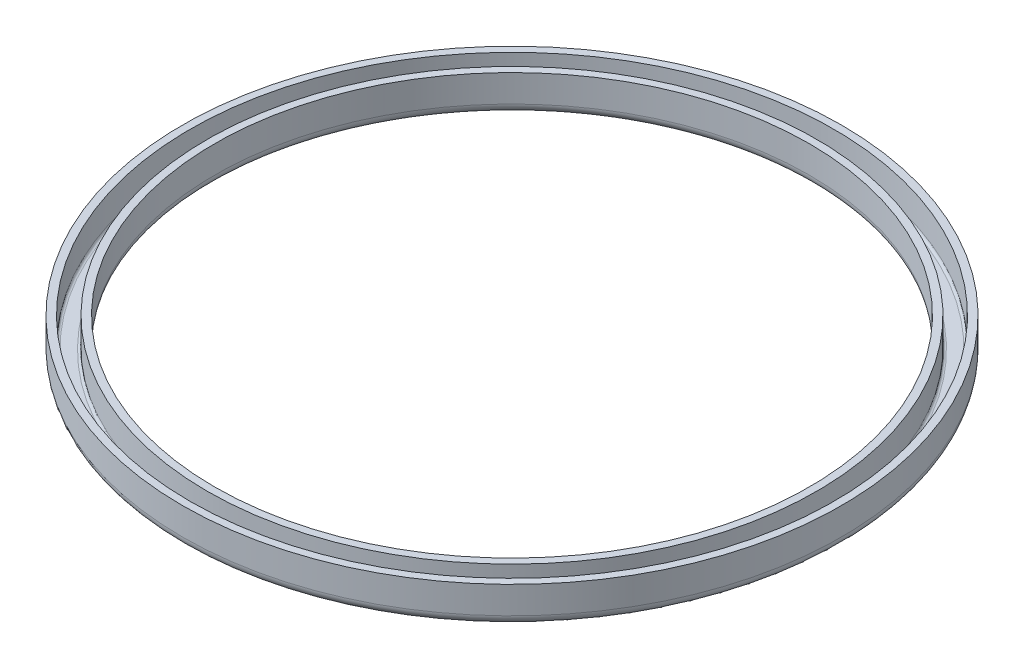
from build123d import *


with BuildPart() as part:
    # Sketch1 → Revolve-Thin1 (revolve)
    with BuildSketch(Plane.XY):
        with BuildLine():
            Line((-6.65, 0.75), (-6.65, 0.2))
            ThreePointArc((-6.65, 0.2), (-6.591421356, 0.058578644), (-6.45, 0))
            Line((-6.45, 0), (-6.2, 0))
            ThreePointArc((-6.2, 0), (-6.058578644, 0.058578644), (-6, 0.2))
            Line((-6, 0.2), (-6, 0.75))
            Line((-6, 0.75), (-6.15, 0.75))
            Line((-6.15, 0.75), (-6.15, 0.2))
            ThreePointArc((-6.15, 0.2), (-6.164644661, 0.164644661), (-6.2, 0.15))
            Line((-6.2, 0.15), (-6.45, 0.15))
            ThreePointArc((-6.45, 0.15), (-6.485355339, 0.164644661), (-6.5, 0.2))
            Line((-6.5, 0.2), (-6.5, 0.75))
            Line((-6.5, 0.75), (-6.65, 0.75))
        make_face()
    revolve(axis=Axis((0, 25.194951605, 0), (0, -1, 0)))


solid = part.part
